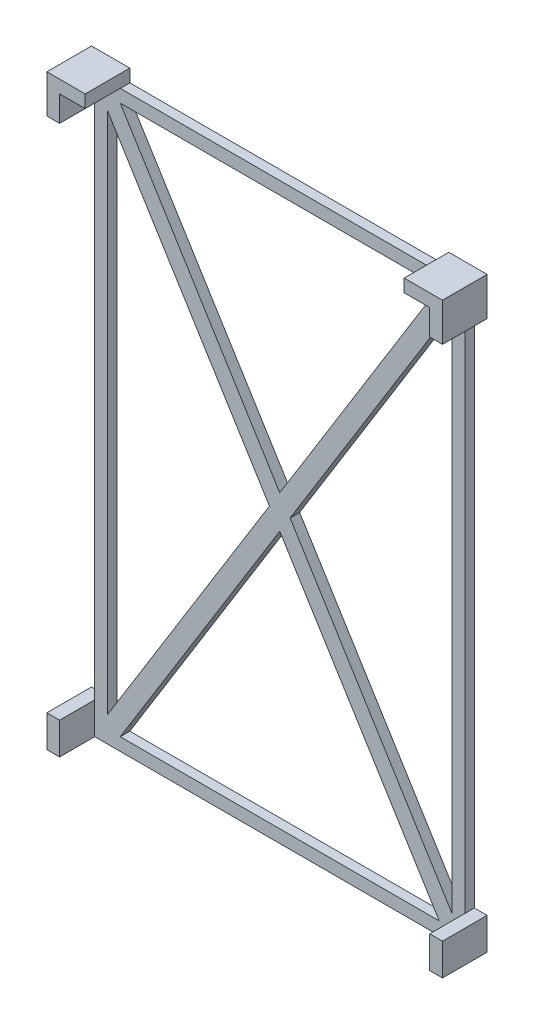
from build123d import *

# Parameters (mm, degrees)
CROQUIS1_W              = 58
CROQUIS1_H              = 90
CROQUIS1_W_2            = 54
CROQUIS1_H_2            = 86
SALIENTE_EXTRUIR1_DEPTH = 1.5
CROQUIS2_W              = 2
CROQUIS2_H              = 5
SALIENTE_EXTRUIR2_DEPTH = 7
SALIENTE_EXTRUIR3_START = -1.5
SALIENTE_EXTRUIR3_DEPTH = 1.5


with BuildPart() as part:
    # Croquis1 → Saliente-Extruir1 (new body)
    with BuildSketch(Plane.XY):
        with Locations((-67.00177265, -15.055922694)):
            Rectangle(CROQUIS1_W, CROQUIS1_H)
        with Locations((-67.00177265, -15.055922694)):
            Rectangle(CROQUIS1_W_2, CROQUIS1_H_2, mode=Mode.SUBTRACT)
    extrude(amount=SALIENTE_EXTRUIR1_DEPTH)

    # Croquis2 → Saliente-Extruir2 (add)
    with BuildSketch(Plane(origin=(0, 0, 0), x_dir=(-1, 0, 0), z_dir=(0, 0, -1))):
        with Locations((37.00177265, -57.555922694)):
            Rectangle(CROQUIS2_W, CROQUIS2_H)
        Polygon((38.00177265, 29.944077306), (38.00177265, 25.944077306), (36.00177265, 25.944077306), (36.00177265, 31.944077306), (42.00177265, 31.944077306), (42.00177265, 29.944077306), align=None)
        Polygon((92.00177265, 29.944077306), (96.00177265, 29.944077306), (96.00177265, 25.944077306), (98.00177265, 25.944077306), (98.00177265, 31.944077306), (92.00177265, 31.944077306), align=None)
        with Locations((97.00177265, -57.555922694)):
            Rectangle(CROQUIS2_W, CROQUIS2_H)
    extrude(amount=-SALIENTE_EXTRUIR2_DEPTH)

    # Croquis3 → Saliente-Extruir3 (add)
    with BuildSketch(Plane(origin=(0, 0, 0), x_dir=(-1, 0, 0), z_dir=(0, 0, -1)).offset(SALIENTE_EXTRUIR3_START)):
        Polygon((94.00177265, -56.055922694), (68.620820269, -15.055922694), (94.00177265, 25.944077306), (94.00177265, 27.944077306), (92.00177265, 27.944077306), (67.00177265, -12.440538078), (42.00177265, 27.944077306), (40.00177265, 27.944077306), (40.00177265, 25.944077306), (65.382725031, -15.055922694), (40.00177265, -56.055922694), (40.00177265, -58.055922694), (42.00177265, -58.055922694), (67.00177265, -17.671307309), (92.00177265, -58.055922694), (94.00177265, -58.055922694), align=None)
    extrude(amount=SALIENTE_EXTRUIR3_DEPTH)


solid = part.part
